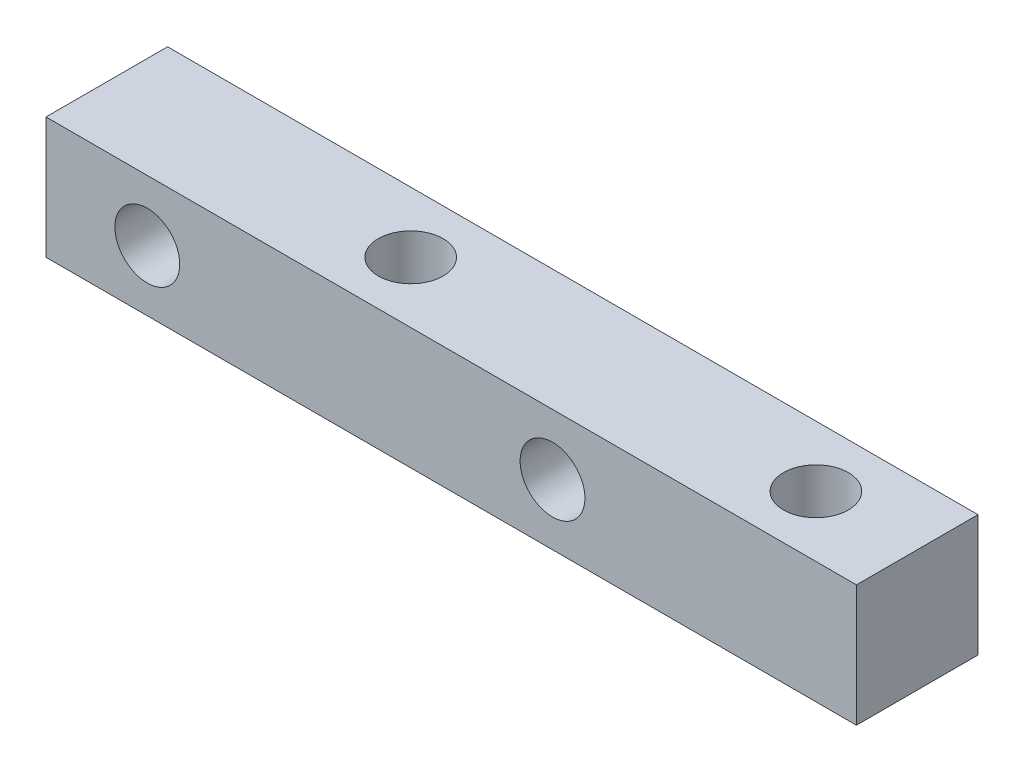
from build123d import *

# Parameters (mm, degrees)
SKETCH_1_W          = 40
SKETCH_1_H          = 6
SKETCH_1_R          = 1.6
EXTRUDE_1_DEPTH     = 6
SKETCH_2_R          = 1.6
CUT_EXTRUDE_1_DEPTH = 6


with BuildPart() as part:
    # 草图1 → 凸台-拉伸1 (new body)
    with BuildSketch(Plane.XY):
        with Locations((20, 3)):
            Rectangle(SKETCH_1_W, SKETCH_1_H)
        with Locations((5, 3)):
            Circle(SKETCH_1_R, mode=Mode.SUBTRACT)
        with Locations((25, 3)):
            Circle(SKETCH_1_R, mode=Mode.SUBTRACT)
    extrude(amount=EXTRUDE_1_DEPTH)

    # 草图2 → 切除-拉伸1 (cut)
    with BuildSketch(Plane(origin=(0, 6, 0), x_dir=(1, 0, 0), z_dir=(0, 1, 0))):
        with Locations((35, -3)):
            Circle(SKETCH_2_R)
        with Locations((15, -3)):
            Circle(SKETCH_2_R)
    extrude(amount=-CUT_EXTRUDE_1_DEPTH, mode=Mode.SUBTRACT)


solid = part.part
